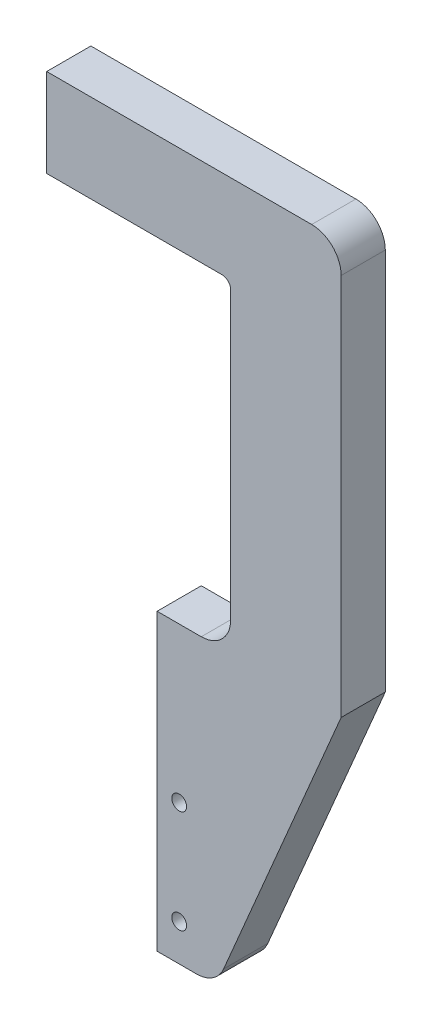
from build123d import *

# Parameters (mm, degrees)
EXTRUDE_1_DEPTH        = 7.5
HOLE_WIZARD_M8_1_D     = 6.8
HOLE_WIZARD_M8_1_DEPTH = 19.75
HOLE_WIZARD_M8_1_TIP   = 2.042926105
HOLE_WIZARD_M8_2_D     = 6.8
HOLE_WIZARD_M8_2_DEPTH = 19.75
HOLE_WIZARD_M8_2_TIP   = 2.042926105
FILLET_1_R             = 10
FILLET_2_R             = 3
HOLE_WIZARD_M6_1_D     = 5


with BuildPart() as part:
    # 草图1 → 凸台-拉伸1 (new body, symmetric)
    with BuildSketch(Plane.XY):
        with BuildLine():
            Line((0, 0), (0, 30))
            Line((0, 30), (90, 30))
            ThreePointArc((90, 30), (97.071067812, 27.071067812), (100, 20))
            Line((100, 20), (100, -110))
            Line((100, -110), (57.5, -210))
            Line((57.5, -210), (37.5, -210))
            Line((37.5, -210), (37.5, -110))
            Line((37.5, -110), (62.5, -110))
            Line((62.5, -110), (62.5, 0))
            Line((62.5, 0), (0, 0))
        make_face()
    extrude(amount=EXTRUDE_1_DEPTH, both=True)

    # M8 螺纹孔1
    with Locations(Plane(origin=(0, 0, 0), x_dir=(-1, 0, 0), z_dir=(0, -1, 0))):
        with Locations((-40, 0), (-10, 0)):
            Hole(HOLE_WIZARD_M8_1_D / 2, depth=HOLE_WIZARD_M8_1_DEPTH)
            with Locations((0, 0, -(HOLE_WIZARD_M8_1_DEPTH + HOLE_WIZARD_M8_1_TIP / 2))):  # 118° drill point
                Cone(0, HOLE_WIZARD_M8_1_D / 2, HOLE_WIZARD_M8_1_TIP, mode=Mode.SUBTRACT)

    # M8 螺纹孔2
    with Locations(Plane.ZY.offset(-37.5)):
        with Locations((0, -130), (0, -190)):
            Hole(HOLE_WIZARD_M8_2_D / 2, depth=HOLE_WIZARD_M8_2_DEPTH)
            with Locations((0, 0, -(HOLE_WIZARD_M8_2_DEPTH + HOLE_WIZARD_M8_2_TIP / 2))):  # 118° drill point
                Cone(0, HOLE_WIZARD_M8_2_D / 2, HOLE_WIZARD_M8_2_TIP, mode=Mode.SUBTRACT)

    # 圆角1
    fillet_1_edges = [part.edges().sort_by_distance(p)[0] for p in [
        (57.5, -210, 0),
        (62.5, -110, 0),
    ]]
    fillet(fillet_1_edges, radius=FILLET_1_R)

    # 圆角2
    fillet_2_edges = [part.edges().sort_by_distance(p)[0] for p in [
        (62.5, 0, 0),
    ]]
    fillet(fillet_2_edges, radius=FILLET_2_R)

    # M6 螺纹孔1 (through all)
    with Locations(Plane(origin=(45, -162.5, 7.5), x_dir=(1, 0, 0), z_dir=(0, 0, 1))):
        with Locations((0, 0), (0, -35)):
            Hole(HOLE_WIZARD_M6_1_D / 2)


solid = part.part
